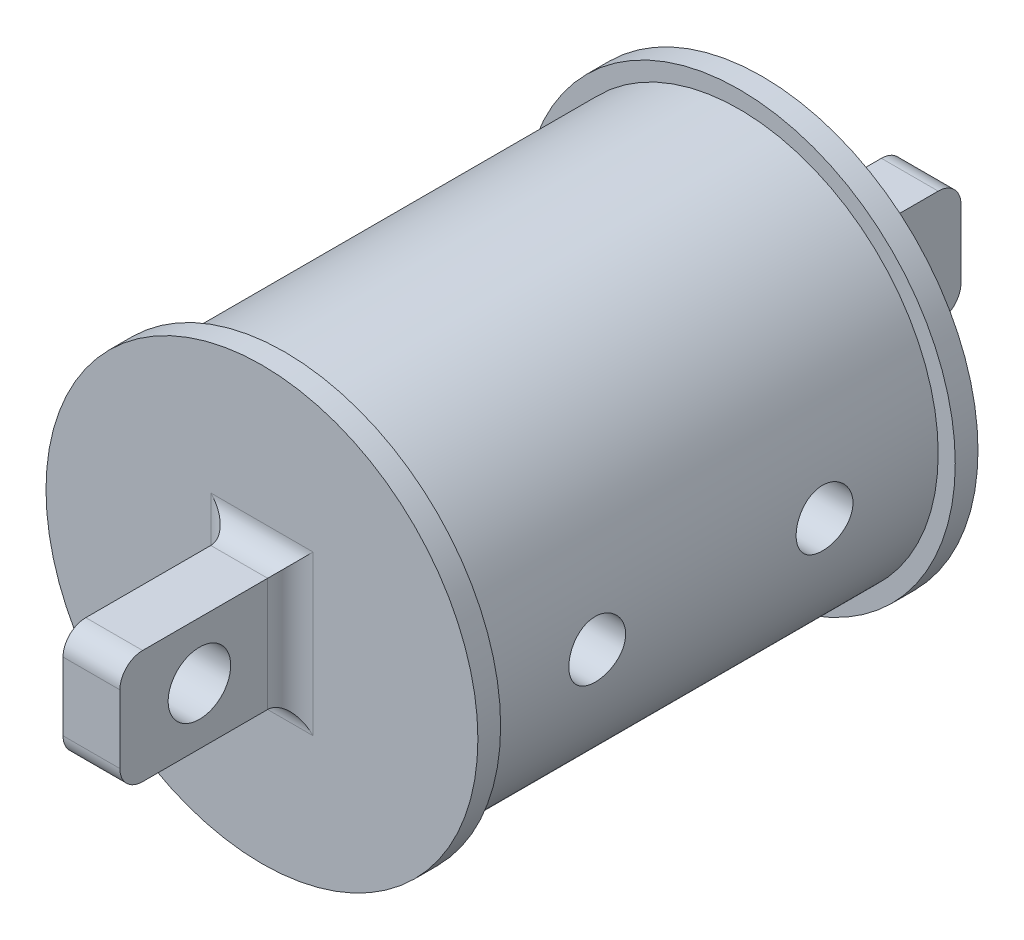
from build123d import *

# Parameters (mm, degrees)
SKETCH1_R               = 22.225
BOSS_EXTRUDE1_DEPTH     = 25.4
SKETCH2_R               = 24.13
BOSS_EXTRUDE2_DEPTH     = 2.54
SKETCH3_W               = 6.35
SKETCH3_H               = 12.7
BOSS_EXTRUDE3_DEPTH     = 19.05
SKETCH4_R               = 3.4925
CUT_EXTRUDE1_DEPTH      = 28.305
FILLET1_R               = 2.54
FILLET1_OF_MIRROR1_R    = 2.54
SKETCH5_R               = 3.175
CUT_EXTRUDE2_DEPTH      = 25.13
CUT_EXTRUDE2_DEPTH_BACK = 25.13


with BuildPart() as part:
    # Sketch1 → Boss-Extrude1 (new body, symmetric)
    with BuildSketch(Plane.XY):
        Circle(SKETCH1_R)
    extrude(amount=BOSS_EXTRUDE1_DEPTH, both=True)

    # Sketch2 → Boss-Extrude2 (add)
    with BuildSketch(Plane.XY.offset(25.4)):
        Circle(SKETCH2_R)
    boss_extrude2 = extrude(amount=BOSS_EXTRUDE2_DEPTH)

    # Sketch3 → Boss-Extrude3 (add)
    with BuildSketch(Plane.XY.offset(27.94)):
        Rectangle(SKETCH3_W, SKETCH3_H)
    boss_extrude3 = extrude(amount=BOSS_EXTRUDE3_DEPTH)

    # Sketch4 → Cut-Extrude1 (cut, through all)
    with BuildSketch(Plane(origin=(3.175, 0, 0), x_dir=(0, 0, -1), z_dir=(1, 0, 0))):
        with Locations((-38.1, 0)):
            Circle(SKETCH4_R)
    cut_extrude1 = extrude(amount=-CUT_EXTRUDE1_DEPTH, mode=Mode.SUBTRACT)

    # Fillet1
    fillet1_edges = [part.edges().sort_by_distance(p)[0] for p in [
        (3.175, 0, 27.94),
        (0, 6.35, 27.94),
        (-3.175, 0, 27.94),
        (0, -6.35, 27.94),
        (0, 6.35, 46.99),
        (0, -6.35, 46.99),
    ]]
    fillet(fillet1_edges, radius=FILLET1_R)

    # Mirror1: Boss-Extrude2, Boss-Extrude3, Cut-Extrude1 across plane
    add(boss_extrude2.mirror(Plane.XY))
    add(boss_extrude3.mirror(Plane.XY))
    add(cut_extrude1.mirror(Plane.XY), mode=Mode.SUBTRACT)

    # Fillet1 of Mirror1
    fillet1_of_mirror1_edges = [part.edges().sort_by_distance(p)[0] for p in [
        (3.175, 0, -27.94),
        (0, 6.35, -27.94),
        (-3.175, 0, -27.94),
        (0, -6.35, -27.94),
        (0, 6.35, -46.99),
        (0, -6.35, -46.99),
    ]]
    fillet(fillet1_of_mirror1_edges, radius=FILLET1_OF_MIRROR1_R)

    # Sketch5 → Cut-Extrude2 (cut, two sides)
    with BuildSketch(Plane(origin=(0, 0, 0), x_dir=(0, 0, -1), z_dir=(1, 0, 0))) as cut_extrude2_sk:
        with Locations((-12.7, 0)):
            Circle(SKETCH5_R)
        with Locations((12.7, 0)):
            Circle(SKETCH5_R)
    extrude(amount=CUT_EXTRUDE2_DEPTH, mode=Mode.SUBTRACT)
    extrude(cut_extrude2_sk.sketch, amount=-CUT_EXTRUDE2_DEPTH_BACK, mode=Mode.SUBTRACT)


solid = part.part
